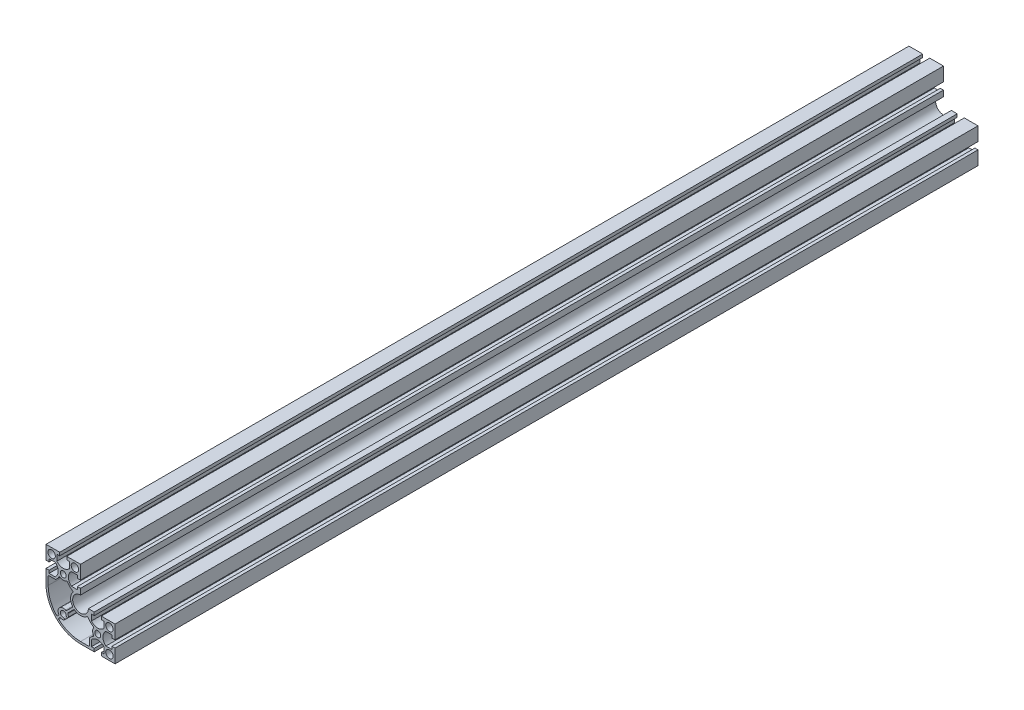
from build123d import *

# Parameters (mm, degrees)
SKETCH_1_R      = 3.4
SKETCH_1_R_2    = 4.3
EXTRUDE_1_DEPTH = 1000


with BuildPart() as part:
    # Эскиз1 → Бобышка-Вытянуть1 (new body)
    with BuildSketch(Plane.XY):
        with BuildLine():
            Line((-20, 47.35), (-20, 60))
            Line((-20, 60), (-7.35, 60))
            Line((-7.35, 60), (-4.1, 60))
            Line((-4.1, 60), (-4.1, 56.4))
            Line((-4.1, 56.4), (-7.35, 56.4))
            Line((-7.35, 56.4), (-7.35, 49.4))
            ThreePointArc((-7.35, 49.4), (0, 45.918928476), (7.35, 49.4))
            Line((7.35, 49.4), (7.35, 56.4))
            Line((7.35, 56.4), (4.1, 56.4))
            Line((4.1, 56.4), (4.1, 60))
            Line((4.1, 60), (7.35, 60))
            Line((7.35, 60), (20, 60))
            Line((20, 60), (20, 47.35))
            Line((20, 47.35), (20, 44.1))
            Line((20, 44.1), (16.4, 44.1))
            Line((16.4, 44.1), (16.4, 47.35))
            Line((16.4, 47.35), (9.4, 47.35))
            ThreePointArc((9.4, 47.35), (5.918928476, 40), (9.4, 32.65))
            Line((9.4, 32.65), (16.4, 32.65))
            Line((16.4, 32.65), (16.4, 35.9))
            Line((16.4, 35.9), (20, 35.9))
            Line((20, 35.9), (20, 32.65))
            Line((20, 32.65), (20, 29.1))
            ThreePointArc((20, 29.1), (13.565328291, 13.565328291), (29.1, 20))
            Line((29.1, 20), (32.65, 20))
            Line((32.65, 20), (35.9, 20))
            Line((35.9, 20), (35.9, 16.4))
            Line((35.9, 16.4), (32.65, 16.4))
            Line((32.65, 16.4), (32.65, 9.4))
            ThreePointArc((32.65, 9.4), (40, 5.918928476), (47.35, 9.4))
            Line((47.35, 9.4), (47.35, 16.4))
            Line((47.35, 16.4), (44.1, 16.4))
            Line((44.1, 16.4), (44.1, 20))
            Line((44.1, 20), (47.35, 20))
            Line((47.35, 20), (60, 20))
            Line((60, 20), (60, 7.35))
            Line((60, 7.35), (60, 4.1))
            Line((60, 4.1), (56.4, 4.1))
            Line((56.4, 4.1), (56.4, 7.35))
            Line((56.4, 7.35), (49.4, 7.35))
            ThreePointArc((49.4, 7.35), (45.918928476, 0), (49.4, -7.35))
            Line((49.4, -7.35), (56.4, -7.35))
            Line((56.4, -7.35), (56.4, -4.1))
            Line((56.4, -4.1), (60, -4.1))
            Line((60, -4.1), (60, -7.35))
            Line((60, -7.35), (60, -20))
            Line((60, -20), (47.35, -20))
            Line((47.35, -20), (44.1, -20))
            Line((44.1, -20), (44.1, -16.4))
            Line((44.1, -16.4), (47.35, -16.4))
            Line((47.35, -16.4), (47.35, -9.4))
            ThreePointArc((47.35, -9.4), (40, -5.918928476), (32.65, -9.4))
            Line((32.65, -9.4), (32.65, -16.4))
            Line((32.65, -16.4), (35.9, -16.4))
            Line((35.9, -16.4), (35.9, -20))
            Line((35.9, -20), (32.65, -20))
            Line((32.65, -20), (20, -20))
            ThreePointArc((20, -20), (-8.284271247, -8.284271247), (-20, 20))
            Line((-20, 20), (-20, 32.65))
            Line((-20, 32.65), (-20, 35.9))
            Line((-20, 35.9), (-16.4, 35.9))
            Line((-16.4, 35.9), (-16.4, 32.65))
            Line((-16.4, 32.65), (-9.4, 32.65))
            ThreePointArc((-9.4, 32.65), (-5.918928476, 40), (-9.4, 47.35))
            Line((-9.4, 47.35), (-16.4, 47.35))
            Line((-16.4, 47.35), (-16.4, 44.1))
            Line((-16.4, 44.1), (-20, 44.1))
            Line((-20, 44.1), (-20, 47.35))
        make_face()
        with Locations((0, 40)):
            Circle(SKETCH_1_R, mode=Mode.SUBTRACT)
        with Locations((-13.5, 53.5)):
            Circle(SKETCH_1_R_2, mode=Mode.SUBTRACT)
        with Locations((13.5, 53.5)):
            Circle(SKETCH_1_R_2, mode=Mode.SUBTRACT)
        with Locations((40, 0)):
            Circle(SKETCH_1_R, mode=Mode.SUBTRACT)
        with Locations((53.5, 13.5)):
            Circle(SKETCH_1_R_2, mode=Mode.SUBTRACT)
        with Locations((53.5, -13.5)):
            Circle(SKETCH_1_R_2, mode=Mode.SUBTRACT)
        with BuildLine():
            Line((-16.5, 30.25), (-8.9, 30.25))
            ThreePointArc((-8.9, 30.25), (-6.700552447, 32.329425303), (-4.963344147, 34.808071396))
            ThreePointArc((-4.963344147, 34.808071396), (-4.307204214, 35.295967153), (-3.506330333, 35.131155415))
            ThreePointArc((-3.506330333, 35.131155415), (-0.007297066, 34.000004437), (3.494477209, 35.122641182))
            ThreePointArc((3.494477209, 35.122641182), (4.300644961, 35.284393495), (4.955538691, 34.787217011))
            ThreePointArc((4.955538691, 34.787217011), (7.479168525, 31.392379507), (10.850248541, 28.837100905))
            ThreePointArc((10.850248541, 28.837100905), (11.347237818, 28.148388812), (11.135414137, 27.32592093))
            ThreePointArc((11.135414137, 27.32592093), (8.507881499, 20.42569046), (10.617718004, 13.349978606))
            ThreePointArc((10.617718004, 13.349978606), (10.798307809, 12.687415803), (10.508974176, 12.064609095))
            Line((10.508974176, 12.064609095), (3.943940688, 5.499575606))
            ThreePointArc((3.943940688, 5.499575606), (3.388591606, 5.218264662), (2.774429063, 5.320013475))
            ThreePointArc((2.774429063, 5.320013475), (-4.242640687, 4.242640687), (-5.320013475, -2.774429063))
            ThreePointArc((-5.320013475, -2.774429063), (-5.218264662, -3.388591606), (-5.499575606, -3.943940688))
            Line((-5.499575606, -3.943940688), (-6.633181618, -5.0775467))
            ThreePointArc((-6.633181618, -5.0775467), (-7.373462786, -5.369889497), (-8.092728627, -5.029100457))
            ThreePointArc((-8.092728627, -5.029100457), (-15.070519309, 6.630700987), (-17.5, 20))
            Line((-17.5, 20), (-17.5, 29.25))
            ThreePointArc((-17.5, 29.25), (-17.207106781, 29.957106781), (-16.5, 30.25))
        make_face(mode=Mode.SUBTRACT)
        with BuildLine():
            Line((29.25, -17.5), (20, -17.5))
            ThreePointArc((20, -17.5), (6.630700987, -15.070519309), (-5.029100457, -8.092728627))
            ThreePointArc((-5.029100457, -8.092728627), (-5.369889497, -7.373462786), (-5.0775467, -6.633181618))
            Line((-5.0775467, -6.633181618), (-3.943940688, -5.499575606))
            ThreePointArc((-3.943940688, -5.499575606), (-3.388591606, -5.218264662), (-2.774429063, -5.320013475))
            ThreePointArc((-2.774429063, -5.320013475), (-1.428271534, -5.827524382), (0, -6))
            ThreePointArc((0, -6), (1.3, -4.7), (0, -3.4))
            ThreePointArc((0, -3.4), (-2.404163056, 2.404163056), (3.4, 0))
            ThreePointArc((3.4, 0), (4.7, -1.3), (6, 0))
            ThreePointArc((6, 0), (5.827524382, 1.428271534), (5.320013475, 2.774429063))
            ThreePointArc((5.320013475, 2.774429063), (5.218264662, 3.388591606), (5.499575606, 3.943940688))
            Line((5.499575606, 3.943940688), (12.064609095, 10.508974176))
            ThreePointArc((12.064609095, 10.508974176), (12.687415803, 10.798307809), (13.349978606, 10.617718004))
            ThreePointArc((13.349978606, 10.617718004), (20.42569046, 8.507881499), (27.32592093, 11.135414137))
            ThreePointArc((27.32592093, 11.135414137), (28.148388812, 11.347237818), (28.837100905, 10.850248541))
            ThreePointArc((28.837100905, 10.850248541), (31.392379507, 7.479168525), (34.787217011, 4.955538691))
            ThreePointArc((34.787217011, 4.955538691), (35.284393495, 4.300644961), (35.122641182, 3.494477209))
            ThreePointArc((35.122641182, 3.494477209), (34.000004437, -0.007297066), (35.131155415, -3.506330333))
            ThreePointArc((35.131155415, -3.506330333), (35.295967153, -4.307204214), (34.808071396, -4.963344147))
            ThreePointArc((34.808071396, -4.963344147), (32.329425303, -6.700552447), (30.25, -8.9))
            Line((30.25, -8.9), (30.25, -16.5))
            ThreePointArc((30.25, -16.5), (29.957106781, -17.207106781), (29.25, -17.5))
        make_face(mode=Mode.SUBTRACT)
    extrude(amount=EXTRUDE_1_DEPTH)


solid = part.part
